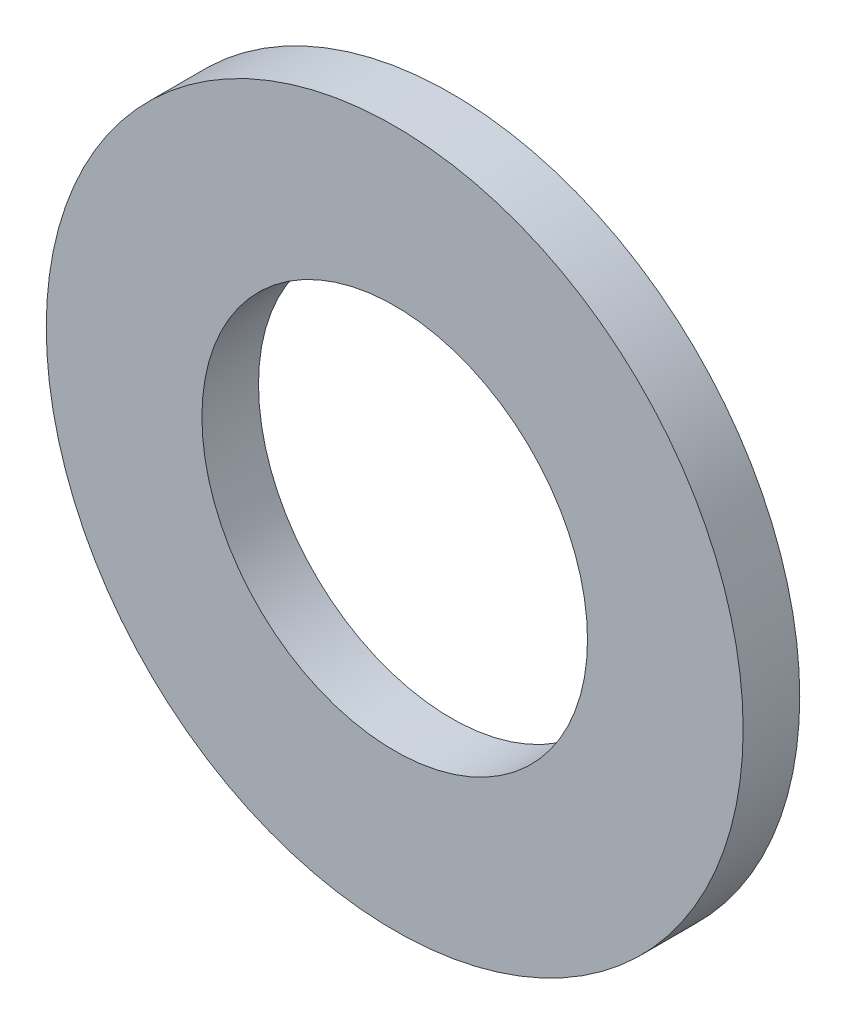
from build123d import *

# Parameters (mm, degrees)
SKETCH3_R           = 9.85
SKETCH3_R_2         = 5.45
BOSS_EXTRUDE1_DEPTH = 0.8


with BuildPart() as part:
    # Sketch3 → Boss-Extrude1 (new body, symmetric)
    with BuildSketch(Plane.XY):
        Circle(SKETCH3_R)
        Circle(SKETCH3_R_2, mode=Mode.SUBTRACT)
    extrude(amount=BOSS_EXTRUDE1_DEPTH, both=True)


solid = part.part
